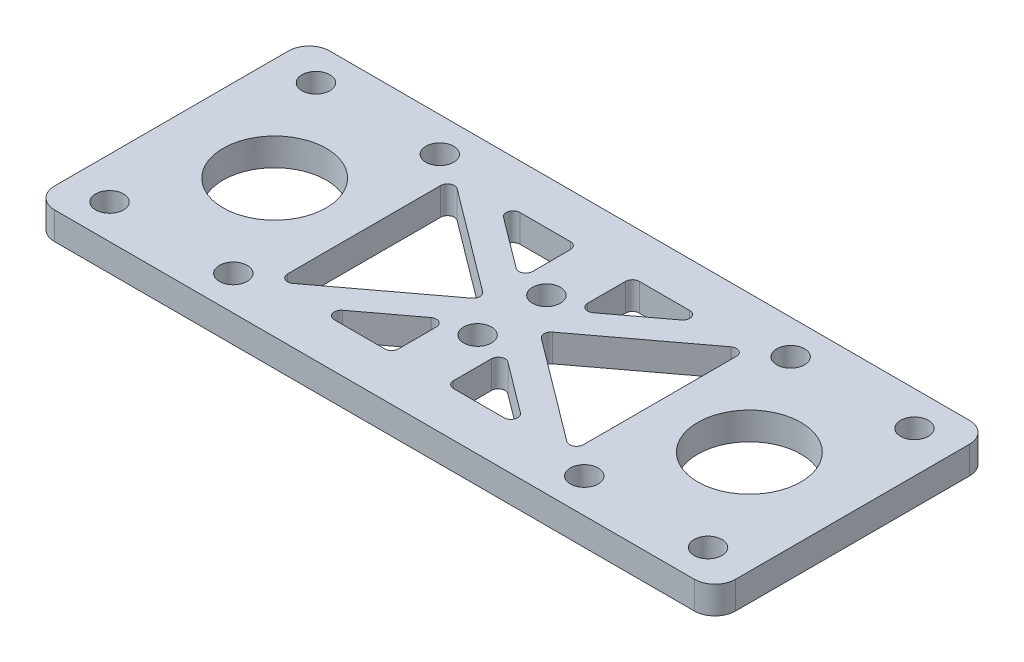
from build123d import *

# Parameters (mm, degrees)
SKETCH_1_W          = 99
SKETCH_1_H          = 40
EXTRUDE_1_DEPTH     = 4
SKETCH_2_R          = 2.025
CUT_EXTRUDE_1_DEPTH = 4
FILLET_1_R          = 3
CUT_EXTRUDE_2_DEPTH = 4
FILLET_2_R          = 1
SKETCH_4_R          = 7.5
CUT_EXTRUDE_3_DEPTH = 4
SKETCH_5_W          = 8
SKETCH_5_H          = 27
EXTRUDE_2_DEPTH     = 4
SKETCH_6_R          = 2.025
CUT_EXTRUDE_4_DEPTH = 4
FILLET_3_R          = 1


with BuildPart() as part:
    # 草图1 → 凸台-拉伸1 (new body)
    with BuildSketch(Plane(origin=(0, 0, 0), x_dir=(1, 0, 0), z_dir=(0, 1, 0))):
        Rectangle(SKETCH_1_W, SKETCH_1_H)
    extrude(amount=EXTRUDE_1_DEPTH)

    # 草图2 → 切除-拉伸1 (cut)
    with BuildSketch(Plane(origin=(0, 4, 0), x_dir=(1, 0, 0), z_dir=(0, 1, 0))):
        with Locations((-43.5, 15)):
            Circle(SKETCH_2_R)
        with Locations((-43.5, -15)):
            Circle(SKETCH_2_R)
        with Locations((-25.5, -15)):
            Circle(SKETCH_2_R)
        with Locations((-25.5, 15)):
            Circle(SKETCH_2_R)
    cut_extrude_1 = extrude(amount=-CUT_EXTRUDE_1_DEPTH, mode=Mode.SUBTRACT)

    # 镜向1: 切除-拉伸1 across plane
    add(cut_extrude_1.mirror(Plane(origin=(0, 0, 0), x_dir=(0, 0, 1), z_dir=(1, 0, 0))), mode=Mode.SUBTRACT)

    # 圆角1
    fillet_1_edges = [part.edges().sort_by_distance(p)[0] for p in [
        (49.5, 2, 20),
        (-49.5, 2, 20),
        (-49.5, 2, -20),
        (49.5, 2, -20),
    ]]
    fillet(fillet_1_edges, radius=FILLET_1_R)

    # 草图3 → 切除-拉伸2 (cut)
    with BuildSketch(Plane(origin=(0, 4, 0), x_dir=(1, 0, 0), z_dir=(0, 1, 0))):
        Polygon((-15.333333333, 13.5), (15.333333333, 13.5), (0, 2), align=None)
        Polygon((-21.5, 13.125), (-21.5, -13.125), (-4, 0), align=None)
        Polygon((-15.333333333, -13.5), (15.333333333, -13.5), (0, -2), align=None)
        Polygon((21.5, 13.125), (21.5, -13.125), (4, 0), align=None)
    extrude(amount=-CUT_EXTRUDE_2_DEPTH, mode=Mode.SUBTRACT)

    # 圆角2
    fillet_2_edges = [part.edges().sort_by_distance(p)[0] for p in [
        (15.333333333, 2, -13.5),
        (-15.333333333, 2, -13.5),
        (0, 2, -2),
        (15.333333333, 2, 13.5),
        (0, 2, 2),
        (-15.333333333, 2, 13.5),
        (-21.5, 2, 13.125),
        (-4, 2, 0),
        (-21.5, 2, -13.125),
        (21.5, 2, 13.125),
        (21.5, 2, -13.125),
        (4, 2, 0),
    ]]
    fillet(fillet_2_edges, radius=FILLET_2_R)

    # 草图4 → 切除-拉伸3 (cut)
    with BuildSketch(Plane(origin=(0, 4, 0), x_dir=(1, 0, 0), z_dir=(0, 1, 0))):
        with Locations((-34.5, 0)):
            Circle(SKETCH_4_R)
    cut_extrude_3 = extrude(amount=-CUT_EXTRUDE_3_DEPTH, mode=Mode.SUBTRACT)

    # 镜向2: 切除-拉伸3 across plane
    add(cut_extrude_3.mirror(Plane(origin=(0, 0, 0), x_dir=(0, 0, 1), z_dir=(1, 0, 0))), mode=Mode.SUBTRACT)

    # 草图5 → 凸台-拉伸2 (add)
    with BuildSketch(Plane(origin=(0, 4, 0), x_dir=(1, 0, 0), z_dir=(0, 1, 0))):
        Rectangle(SKETCH_5_W, SKETCH_5_H)
    extrude(amount=-EXTRUDE_2_DEPTH)

    # 草图6 → 切除-拉伸4 (cut)
    with BuildSketch(Plane(origin=(0, 4, 0), x_dir=(1, 0, 0), z_dir=(0, 1, 0))):
        with Locations((0, 5)):
            Circle(SKETCH_6_R)
        with Locations((0, -5)):
            Circle(SKETCH_6_R)
    extrude(amount=-CUT_EXTRUDE_4_DEPTH, mode=Mode.SUBTRACT)

    # 圆角3
    fillet_3_edges = [part.edges().sort_by_distance(p)[0] for p in [
        (-4, 2, 5),
        (4, 2, 5),
        (4, 2, -13.5),
        (-4, 2, 13.5),
        (-4, 2, -13.5),
        (-4, 2, -5),
        (4, 2, 13.5),
        (4, 2, -5),
    ]]
    fillet(fillet_3_edges, radius=FILLET_3_R)


solid = part.part
